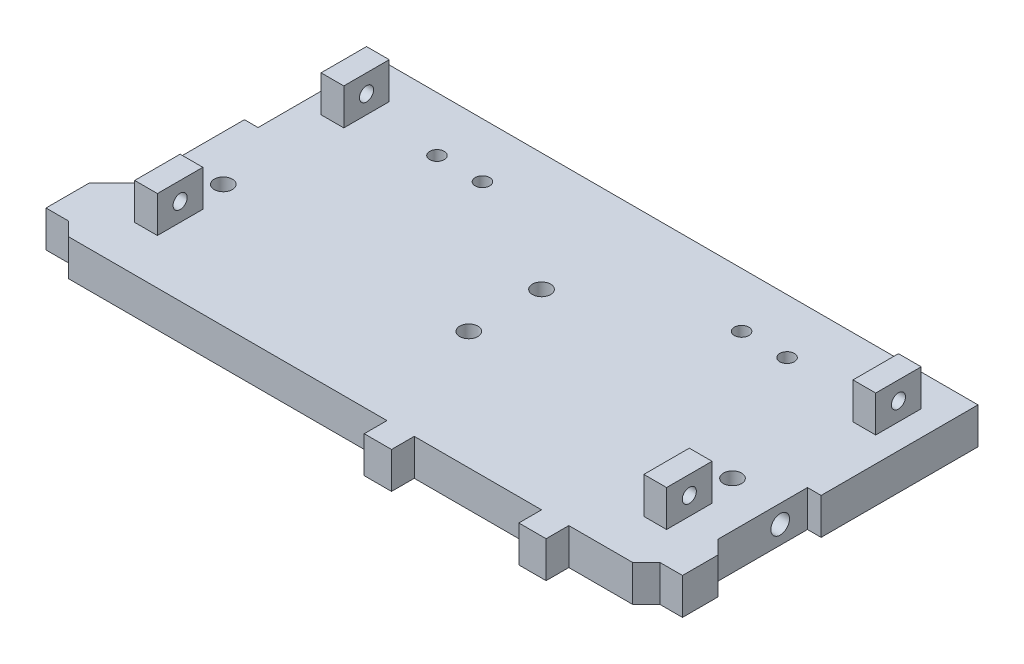
from build123d import *

# Parameters (mm, degrees)
BOSS_EXTRUDE1_DEPTH = 8
SKETCH2_R           = 2
CUT_EXTRUDE1_DEPTH  = 9
SKETCH3_R           = 2
SKETCH3_R_2         = 1.6
CUT_EXTRUDE2_DEPTH  = 9
SKETCH4_R           = 2.05
CUT_EXTRUDE3_DEPTH  = 6
SKETCH5_W           = 5
SKETCH5_H           = 10
BOSS_EXTRUDE2_DEPTH = 8
SKETCH6_R           = 1.55
CUT_EXTRUDE4_DEPTH  = 128.5


with BuildPart() as part:
    # Sketch1 → Boss-Extrude1 (new body)
    with BuildSketch(Plane(origin=(0, 0, 0), x_dir=(1, 0, 0), z_dir=(0, 1, 0))):
        Polygon((70, 34), (-62, 34), (-62, 7.645012604), (-65, 7.645012604), (-65, -16.427077226), (-70, -21.427077226), (-70, -31), (-65, -31), (-62, -34), (8, -34), (8, -39), (14, -39), (14, -34), (42, -34), (42, -39), (48, -39), (48, -34), (62, -34), (65, -31), (70, -31), (70, -23.155364425), (67, -20.155364425), (67, -0.506394588), (70, -0.506394588), align=None)
    extrude(amount=BOSS_EXTRUDE1_DEPTH)

    # Sketch2 → Cut-Extrude1 (cut, through all)
    with BuildSketch(Plane(origin=(0, 8, 0), x_dir=(1, 0, 0), z_dir=(0, 1, 0))):
        with Locations((0, 8)):
            Circle(SKETCH2_R)
        with Locations((0, -8)):
            Circle(SKETCH2_R)
    extrude(amount=-CUT_EXTRUDE1_DEPTH, mode=Mode.SUBTRACT)

    # Sketch3 → Cut-Extrude2 (cut, through all)
    with BuildSketch(Plane(origin=(0, 8, 0), x_dir=(1, 0, 0), z_dir=(0, 1, 0))):
        with Locations((57, -7)):
            Circle(SKETCH3_R)
        with Locations((-37, 22)):
            Circle(SKETCH3_R_2)
        with Locations((-27, 22)):
            Circle(SKETCH3_R_2)
        with Locations((30, 22)):
            Circle(SKETCH3_R_2)
        with Locations((40, 22)):
            Circle(SKETCH3_R_2)
        with Locations((-55, -7)):
            Circle(SKETCH3_R)
    extrude(amount=-CUT_EXTRUDE2_DEPTH, mode=Mode.SUBTRACT)

    # Sketch4 → Cut-Extrude3 (cut)
    with BuildSketch(Plane(origin=(67, 0, 0), x_dir=(0, 0, -1), z_dir=(1, 0, 0))):
        with Locations((-6.506394588, 4)):
            Circle(SKETCH4_R)
    extrude(amount=-CUT_EXTRUDE3_DEPTH, mode=Mode.SUBTRACT)

    # Sketch5 → Boss-Extrude2 (add)
    with BuildSketch(Plane(origin=(0, 8, 0), x_dir=(1, 0, 0), z_dir=(0, 1, 0))):
        with Locations((-55, -19)):
            Rectangle(SKETCH5_W, SKETCH5_H)
        with Locations((-55, 22)):
            Rectangle(SKETCH5_W, SKETCH5_H)
        with Locations((57, -19)):
            Rectangle(SKETCH5_W, SKETCH5_H)
        with Locations((62, 22)):
            Rectangle(SKETCH5_W, SKETCH5_H)
    extrude(amount=BOSS_EXTRUDE2_DEPTH)

    # Sketch6 → Cut-Extrude4 (cut, through all)
    with BuildSketch(Plane.ZY.offset(57.5)):
        with Locations((-22, 12)):
            Circle(SKETCH6_R)
        with Locations((19, 12)):
            Circle(SKETCH6_R)
    extrude(amount=-CUT_EXTRUDE4_DEPTH, mode=Mode.SUBTRACT)


solid = part.part
